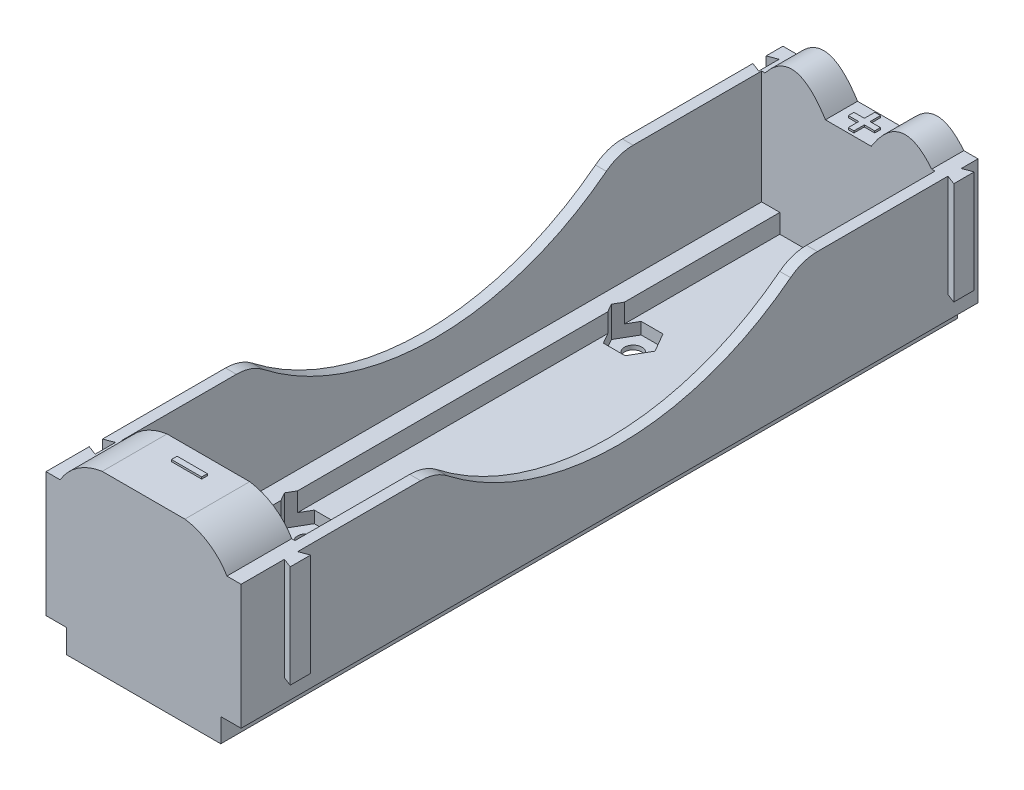
from build123d import *

# Parameters (mm, degrees)
EXTRUDE1_DEPTH       = 40
EXTRUDE2_DEPTH       = 6.86
EXTRUDE3_DEPTH       = 38
SKETCH5_W            = 18.35
SKETCH5_H            = 67.74
EXTRUDE4_DEPTH       = 81.231512798
EXTRUDE4_DEPTH_BACK  = 12
SKETCH6_W            = 14.5
SKETCH6_H            = 67.74
EXTRUDE5_DEPTH       = 2
EXTRUDE6_DEPTH       = 83.825796222
EXTRUDE7_DEPTH       = 10.85
EXTRUDE8_DEPTH       = 10.85
SKETCH10_R           = 0.925
EXTRUDE9_DEPTH       = 82.005837077
EXTRUDE10_DEPTH      = 81.630364259
EXTRUDE10_DEPTH_BACK = 1.25
SKETCH12_W           = 3.2
SKETCH12_H           = 0.6
EXTRUDE11_DEPTH      = 0.2
EXTRUDE12_DEPTH      = 0.2


with BuildPart() as part:
    # Sketch1 → Extrude1 (new body)
    with BuildSketch(Plane.XY):
        Polygon((8.175, 0), (-8.175, 0), (-8.175, 2.5), (-10.325, 2.5), (-10.325, 15.7), (10.325, 15.7), (10.325, 2.5), (8.175, 2.5), align=None)
    extrude(amount=-EXTRUDE1_DEPTH)

    # Sketch2 → Extrude2 (add)
    with BuildSketch(Plane.XY):
        with BuildLine():
            Line((-8.825, 15.7), (8.825, 15.7))
            ThreePointArc((8.825, 15.7), (6.943835072, 17.710022023), (4.375, 18.7))
            Line((4.375, 18.7), (-4.375, 18.7))
            ThreePointArc((-4.375, 18.7), (-6.943835072, 17.710022023), (-8.825, 15.7))
        make_face()
    extrude(amount=-EXTRUDE2_DEPTH)

    # Sketch4 → Extrude3 (add)
    with BuildSketch(Plane(origin=(0, 0, -40), x_dir=(-1, 0, 0), z_dir=(0, 0, -1))):
        with BuildLine():
            Line((-10.325, 15.7), (-8.825, 15.7))
            add(Edge.make_bspline(
                [(-2.425, 14.6), (-5.625, 19.703568586), (-8.825, 15.7)],
                knots=[0, 0, 0, 1, 1, 1], degree=2))
            Line((-2.425, 14.6), (2.425, 14.6))
            add(Edge.make_bspline(
                [(2.425, 14.6), (5.625, 19.703568586), (8.825, 15.7)],
                knots=[0, 0, 0, 1, 1, 1], degree=2))
            Line((8.825, 15.7), (10.325, 15.7))
            Line((10.325, 15.7), (10.325, 2.5))
            Line((10.325, 2.5), (8.175, 2.5))
            Line((8.175, 2.5), (8.175, 0))
            Line((8.175, 0), (-8.175, 0))
            Line((-8.175, 0), (-8.175, 2.5))
            Line((-8.175, 2.5), (-10.325, 2.5))
            Line((-10.325, 2.5), (-10.325, 15.7))
        make_face()
    extrude(amount=EXTRUDE3_DEPTH)

    # Sketch5 → Extrude4 (cut, two sides)
    with BuildSketch(Plane(origin=(0, 15.7, 0), x_dir=(1, 0, 0), z_dir=(0, 1, 0))) as extrude4_sk:
        with Locations((0, 40.73)):
            Rectangle(SKETCH5_W, SKETCH5_H)
    extrude(amount=EXTRUDE4_DEPTH, mode=Mode.SUBTRACT)
    extrude(extrude4_sk.sketch, amount=-EXTRUDE4_DEPTH_BACK, mode=Mode.SUBTRACT)

    # Sketch6 → Extrude5 (cut)
    with BuildSketch(Plane(origin=(0, 3.7, 0), x_dir=(1, 0, 0), z_dir=(0, 1, 0))):
        with Locations((0, 40.73)):
            Rectangle(SKETCH6_W, SKETCH6_H)
    extrude(amount=-EXTRUDE5_DEPTH, mode=Mode.SUBTRACT)

    # Sketch7 → Extrude6 (cut, through all)
    with BuildSketch(Plane(origin=(10.325, 0, 0), x_dir=(0, 0, -1), z_dir=(1, 0, 0))):
        with BuildLine():
            Line((12.066317198, 15.7), (19, 15.7))
            ThreePointArc((19, 15.7), (20.5, 15.45), (21.837837838, 14.727027027))
            ThreePointArc((21.837837838, 14.727027027), (40, 8.5), (58.162162162, 14.727027027))
            ThreePointArc((58.162162162, 14.727027027), (59.5, 15.45), (61, 15.7))
            Line((61, 15.7), (67.933682802, 15.7))
            Line((67.933682802, 15.7), (67.933682802, 19.991069183))
            Line((67.933682802, 19.991069183), (12.066317198, 19.991069183))
            Line((12.066317198, 19.991069183), (12.066317198, 15.7))
        make_face()
    extrude(amount=-EXTRUDE6_DEPTH, mode=Mode.SUBTRACT)

    # Sketch8 → Extrude7 (add)
    with BuildSketch(Plane(origin=(0, 15.7, 0), x_dir=(1, 0, 0), z_dir=(0, 1, 0))):
        Polygon((10.325, 4.58), (10.325, 5.98), (11.325, 6.36), (11.325, 4.2), align=None)
        Polygon((11.325, 76.6), (10.325, 76.22), (10.325, 74.82), (11.325, 74.44), align=None)
    extrude(amount=-EXTRUDE7_DEPTH)

    # Sketch9 → Extrude8 (cut)
    with BuildSketch(Plane(origin=(0, 15.7, 0), x_dir=(1, 0, 0), z_dir=(0, 1, 0))):
        Polygon((-10.325000262, 76.22), (-9.325000262, 76.6), (-9.325000262, 74.44), (-10.325000468, 74.82), align=None)
        Polygon((-10.325000787, 5.98), (-9.325000787, 6.36), (-9.325000787, 4.2), (-10.325000603, 4.58), align=None)
    extrude(amount=-EXTRUDE8_DEPTH, mode=Mode.SUBTRACT)

    # Sketch10 → Extrude9 (cut, through all)
    with BuildSketch(Plane.XZ):
        with Locations(Location((-5.45, -22.675, 0), (0, 0, 270))):
            Circle(SKETCH10_R)
        with Locations(Location((-5.45, -57.275, 0), (0, 0, 270))):
            Circle(SKETCH10_R)
        with Locations(Location((5.45, -57.275, 0), (0, 0, 90))):
            Circle(SKETCH10_R)
        with Locations(Location((5.45, -22.675, 0), (0, 0, 90))):
            Circle(SKETCH10_R)
    extrude(amount=-EXTRUDE9_DEPTH, mode=Mode.SUBTRACT)

    # Sketch11 → Extrude10 (cut, two sides)
    with BuildSketch(Plane(origin=(0, 1.7, 0), x_dir=(1, 0, 0), z_dir=(0, 1, 0))) as extrude10_sk:
        Polygon((-3.140598923, 57.275), (-4.295299462, 59.275), (-6.604700538, 59.275), (-7.759401077, 57.275), (-6.604700538, 55.275), (-4.295299462, 55.275), align=None)
        Polygon((3.140598923, 57.275), (4.295299462, 55.275), (6.604700538, 55.275), (7.759401077, 57.275), (6.604700538, 59.275), (4.295299462, 59.275), align=None)
        Polygon((-3.140598923, 22.675), (-4.295299462, 24.675), (-6.604700538, 24.675), (-7.759401077, 22.675), (-6.604700538, 20.675), (-4.295299462, 20.675), align=None)
        Polygon((3.140598923, 22.675), (4.295299462, 20.675), (6.604700538, 20.675), (7.759401077, 22.675), (6.604700538, 24.675), (4.295299462, 24.675), align=None)
    extrude(amount=EXTRUDE10_DEPTH, mode=Mode.SUBTRACT)
    extrude(extrude10_sk.sketch, amount=-EXTRUDE10_DEPTH_BACK, mode=Mode.SUBTRACT)

    # Sketch12 → Extrude11 (add)
    with BuildSketch(Plane(origin=(0, 18.7, 0), x_dir=(1, 0, 0), z_dir=(0, 1, 0))):
        with Locations((0, 4.853640731)):
            Rectangle(SKETCH12_W, SKETCH12_H)
    extrude(amount=EXTRUDE11_DEPTH)

    # Sketch13 → Extrude12 (add)
    with BuildSketch(Plane(origin=(0, 14.6, 0), x_dir=(1, 0, 0), z_dir=(0, 1, 0))):
        Polygon((-0.3, 77.7), (0.3, 77.7), (0.295752896, 76.599999935), (1.395761159, 76.599999935), (1.395761159, 75.999999935), (0.295752896, 75.999999935), (0.291472262, 74.9), (-0.308527738, 74.9), (-0.304247104, 75.999999935), (-1.404255368, 75.999999935), (-1.404255368, 76.599999935), (-0.304247104, 76.599999935), align=None)
    extrude(amount=EXTRUDE12_DEPTH)


solid = part.part
